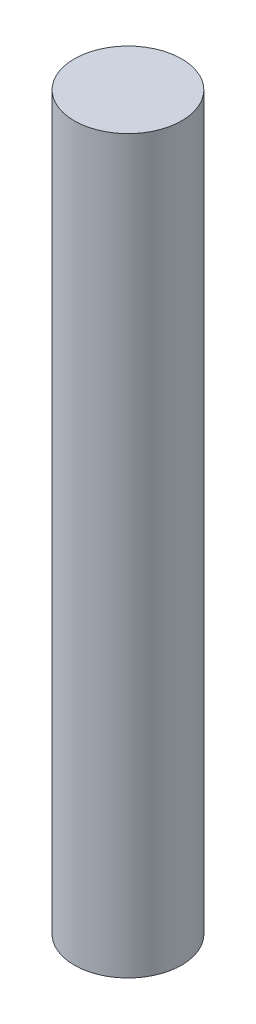
from build123d import *

# Parameters (mm, degrees)
SKETCH1_R           = 1.27
BOSS_EXTRUDE1_DEPTH = 17.2974


with BuildPart() as part:
    # Sketch1 → Boss-Extrude1 (new body)
    with BuildSketch(Plane(origin=(0, 0, 0), x_dir=(1, 0, 0), z_dir=(0, 1, 0))):
        Circle(SKETCH1_R)
    extrude(amount=BOSS_EXTRUDE1_DEPTH)


solid = part.part
